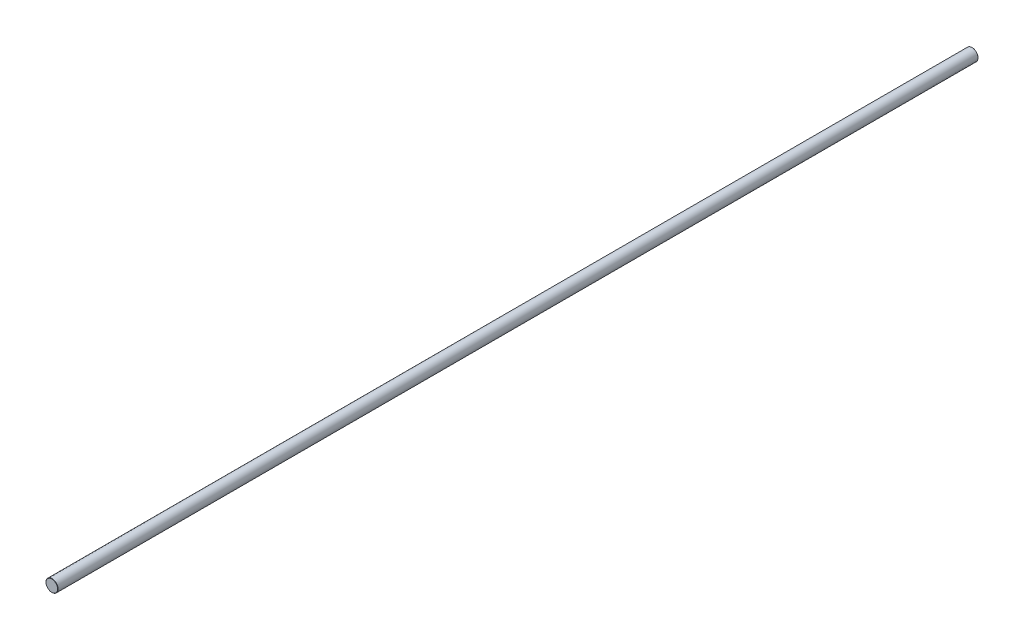
from build123d import *

# Parameters (mm, degrees)
SKETCH3_R                = 8
BOSS_EXTRUDE1_DEPTH      = 610
BOSS_EXTRUDE1_DEPTH_BACK = 610
CHAMFER1_SIZE            = 0.32


with BuildPart() as part:
    # Sketch3 → Boss-Extrude1 (new body, two sides)
    with BuildSketch(Plane.XY) as boss_extrude1_sk:
        Circle(SKETCH3_R)
    extrude(amount=BOSS_EXTRUDE1_DEPTH)
    extrude(boss_extrude1_sk.sketch, amount=-BOSS_EXTRUDE1_DEPTH_BACK)

    # Chamfer1
    chamfer1_edges = [part.edges().sort_by_distance(p)[0] for p in [
        (-8, 0, -610),
        (-8, 0, 610),
    ]]
    chamfer(chamfer1_edges, length=CHAMFER1_SIZE)


solid = part.part
